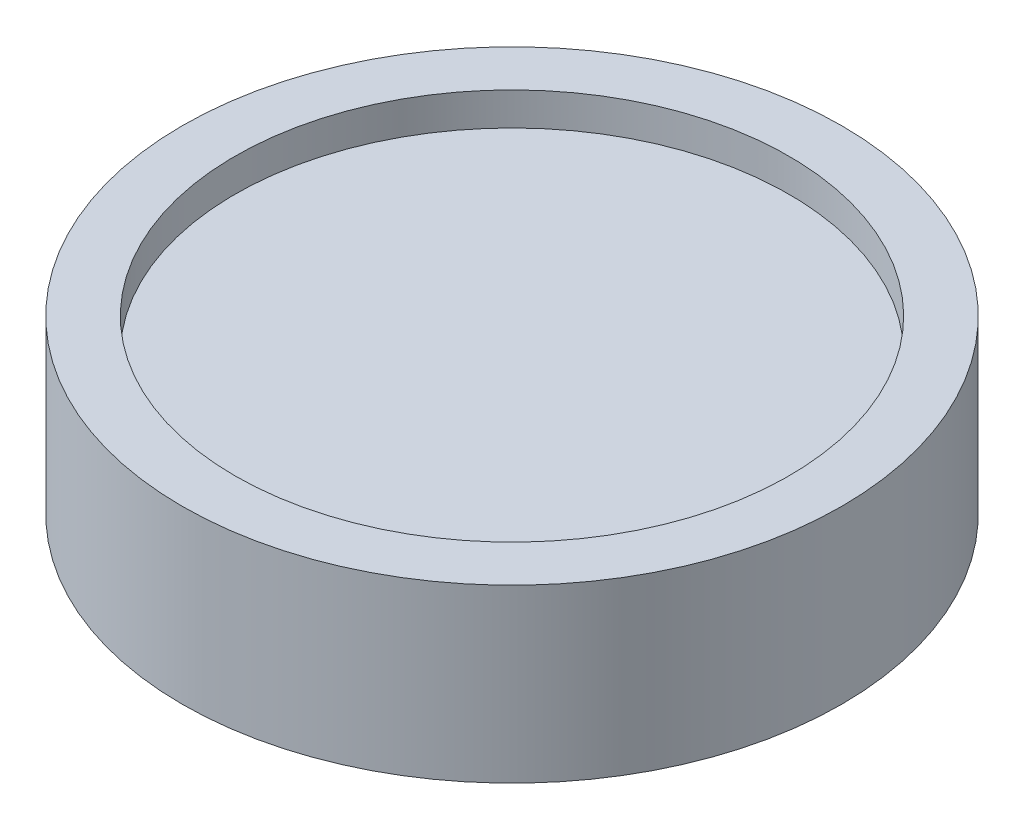
from build123d import *

# Parameters (mm, degrees)
SKETCH1_R                       = 50
BOSS_EXTRUDE1_DEPTH             = 26
SKETCH2_R                       = 42
CUT_EXTRUDE1_DEPTH              = 5
SKETCH3_R                       = 5
HUB_DISTANCE_TO_WORK_WITH_DEPTH = 10


with BuildPart() as part:
    # Sketch1 → Boss-Extrude1 (new body)
    with BuildSketch(Plane(origin=(0, 0, 0), x_dir=(1, 0, 0), z_dir=(0, 1, 0))):
        Circle(SKETCH1_R)
    extrude(amount=BOSS_EXTRUDE1_DEPTH)

    # Sketch2 → Cut-Extrude1 (cut)
    with BuildSketch(Plane(origin=(0, 26, 0), x_dir=(1, 0, 0), z_dir=(0, 1, 0))):
        Circle(SKETCH2_R)
    extrude(amount=-CUT_EXTRUDE1_DEPTH, mode=Mode.SUBTRACT)

    # Sketch3 → hub_distance_to_work_with (add)
    with BuildSketch(Plane.XZ):
        Circle(SKETCH3_R)
    extrude(amount=HUB_DISTANCE_TO_WORK_WITH_DEPTH)


solid = part.part
